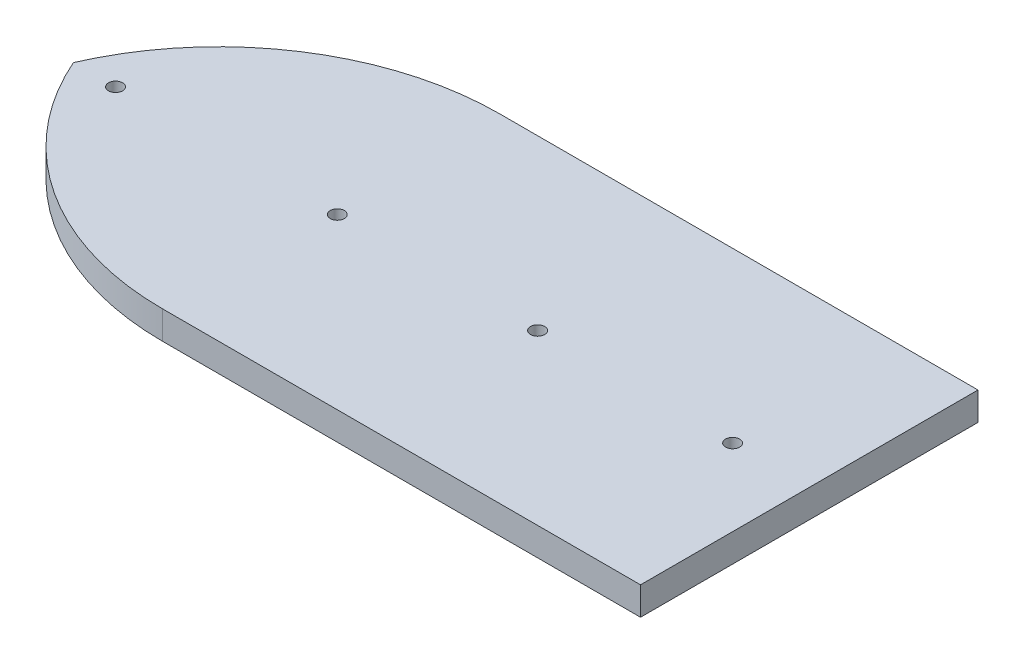
from build123d import *

# Parameters (mm, degrees)
SKETCH1_R           = 0.5
SKETCH1_R_2         = 0.501124618
BOSS_EXTRUDE1_DEPTH = 2


with BuildPart() as part:
    # Sketch1 → Boss-Extrude1 (new body)
    with BuildSketch(Plane(origin=(3.665299607, -3164.606366481, 1.228377955), x_dir=(1, 0, 0), z_dir=(0, 1, 0))):
        with BuildLine():
            Line((28.210288662, -32.620192101), (30.210288662, -32.620192101))
            Line((30.210288662, -32.620192101), (30.210288662, -8.620192101))
            Line((30.210288662, -8.620192101), (28.210288662, -8.620192101))
            Line((28.210288662, -8.620192101), (-3.789711338, -8.620192101))
            ThreePointArc((-3.789711338, -8.620192101), (-14.744162488, -11.88699157), (-22.120014118, -20.620192101))
            ThreePointArc((-22.120014118, -20.620192101), (-14.744162488, -29.353392632), (-3.789711338, -32.620192101))
            Line((-3.789711338, -32.620192101), (28.210288662, -32.620192101))
        make_face()
        with Locations((-19.129616691, -20.617828064)):
            Circle(SKETCH1_R, mode=Mode.SUBTRACT)
        with Locations((24.75459638, -20.617828064)):
            Circle(SKETCH1_R, mode=Mode.SUBTRACT)
        with Locations((10.8879759, -20.617828064)):
            Circle(SKETCH1_R_2, mode=Mode.SUBTRACT)
        with Locations((-3.377772721, -20.597275642)):
            Circle(SKETCH1_R, mode=Mode.SUBTRACT)
    extrude(amount=BOSS_EXTRUDE1_DEPTH)


solid = part.part
